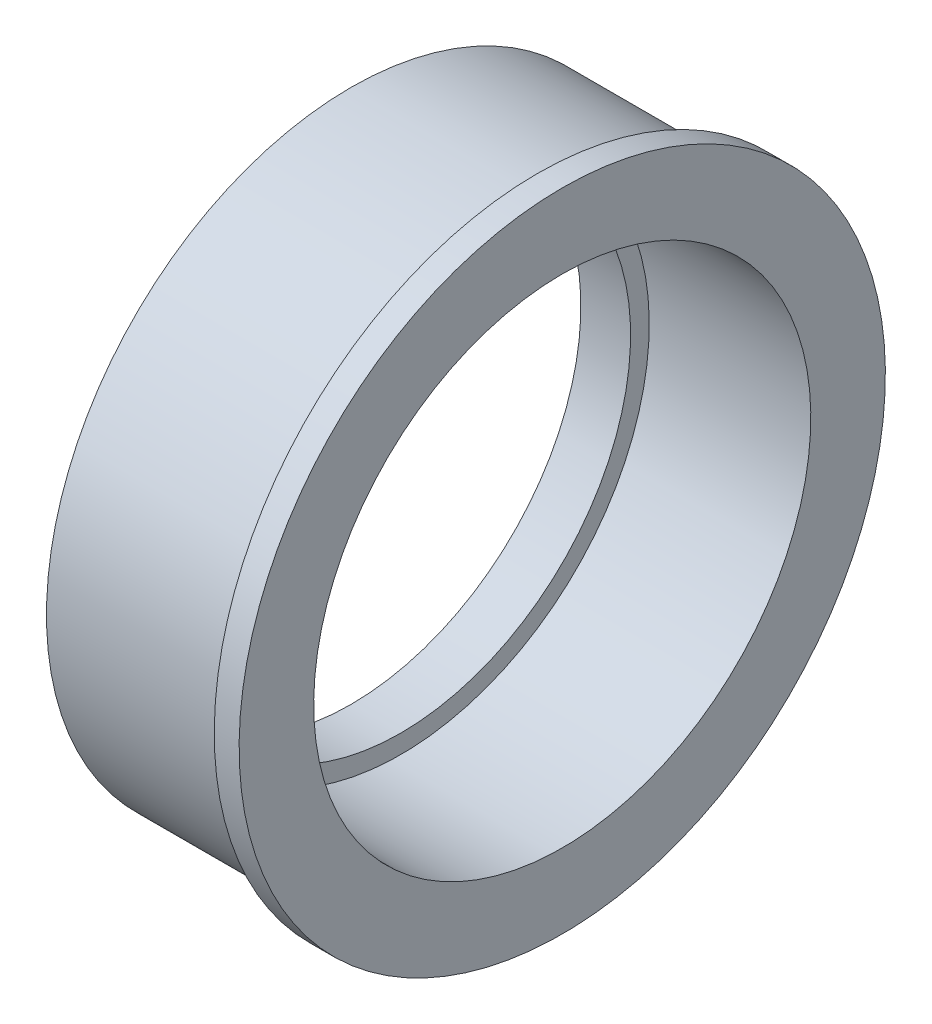
from build123d import *


with BuildPart() as part:
    # Esquisse1 → Révolution8 (revolve)
    with BuildSketch(Plane.XY):
        Polygon((4, 20), (17, 20), (17, 20.05946629), (17, 26), (15, 26), (15, 24.5), (0, 24.5), (0, 18.5), (4, 18.5), align=None)
    revolve(axis=Axis((81.277529183, 0, 0), (-1, 0, 0)))


solid = part.part
